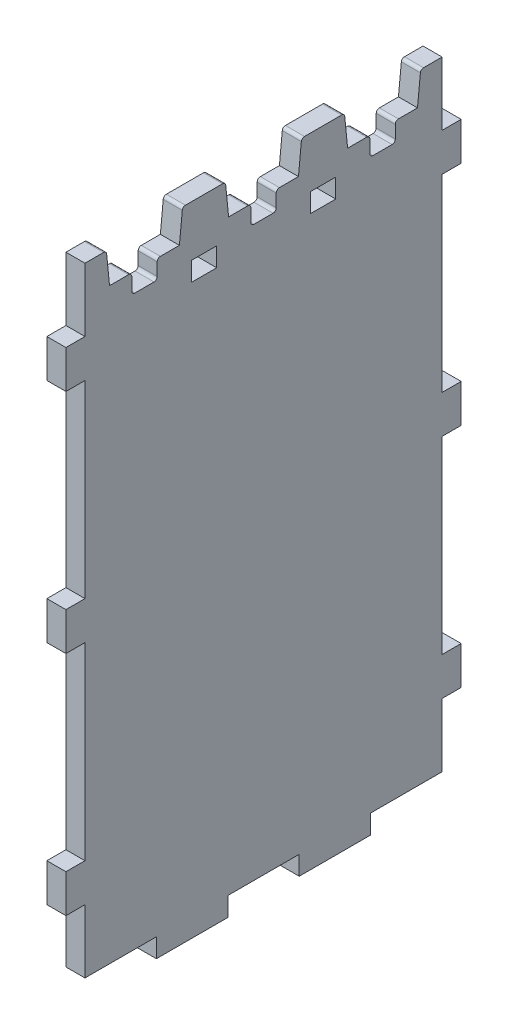
from build123d import *

# Parameters (mm, degrees)
BOSS_EXTRUDE2_DEPTH    = 6
FILLET1_R              = 1
LPATTERN1_COUNT        = 3
LPATTERN1_PITCH        = 37.5
FILLET1_OF_LPATTERN1_R = 1
SKETCH3_W              = 6
SKETCH3_H              = 12
BOSS_EXTRUDE3_DEPTH    = 6
SKETCH4_W              = 8
SKETCH4_H              = 6
CUT_EXTRUDE2_DEPTH     = 7
LPATTERN2_COUNT        = 2
LPATTERN2_PITCH        = 37.5
BOSS_EXTRUDE4_START    = -112.5
SKETCH3_2_W            = 6
SKETCH3_2_H            = 12
BOSS_EXTRUDE4_DEPTH    = 6
SKETCH5_W              = 6
SKETCH5_H              = 22.5
BOSS_EXTRUDE5_DEPTH    = 6


with BuildPart() as part:
    # Sketch2 → Boss-Extrude2 (new body)
    with BuildSketch(Plane(origin=(0, 0, 0), x_dir=(0, 0, -1), z_dir=(1, 0, 0))):
        Polygon((-18.75, 105.5), (-18.75, 89.5), (-18.75, -89.5), (18.75, -89.5), (18.75, 89.5), (18.75, 105.5), (12, 105.5), (11, 95.5), (4, 95.5), (4, 89.5), (-4, 89.5), (-4, 95.5), (-11, 95.5), (-12, 105.5), align=None)
    boss_extrude2 = extrude(amount=BOSS_EXTRUDE2_DEPTH)

    # Fillet1
    fillet1_edges = [part.edges().sort_by_distance(p)[0] for p in [
        (3, 95.5, -4),
        (3, 105.5, -12),
        (3, 105.5, 12),
        (3, 95.5, 4),
        (3, 89.5, 4),
        (3, 89.5, -4),
    ]]
    fillet(fillet1_edges, radius=FILLET1_R)

    # LPattern1: Boss-Extrude2 ×3
    with Locations(*[(0, 0, i * LPATTERN1_PITCH) for i in range(1, LPATTERN1_COUNT)]):
        add(boss_extrude2)

    # Fillet1 of LPattern1
    fillet1_of_lpattern1_edges = [part.edges().sort_by_distance(p)[0] for p in [
        (3, 95.5, 33.5),
        (3, 105.5, 25.5),
        (3, 105.5, 49.5),
        (3, 95.5, 41.5),
        (3, 89.5, 41.5),
        (3, 89.5, 33.5),
        (3, 95.5, 71),
        (3, 105.5, 63),
        (3, 105.5, 87),
        (3, 95.5, 79),
        (3, 89.5, 79),
        (3, 89.5, 71),
    ]]
    fillet(fillet1_of_lpattern1_edges, radius=FILLET1_OF_LPATTERN1_R)

    # Sketch3 → Boss-Extrude3 (add)
    with BuildSketch(Plane(origin=(0, 0, -18.75), x_dir=(-1, 0, 0), z_dir=(0, 0, -1))):
        with Locations((-3, 79.5)):
            Rectangle(SKETCH3_W, SKETCH3_H)
        with Locations((-3, -63.5)):
            Rectangle(SKETCH3_W, SKETCH3_H)
        with Locations((-3, 8)):
            Rectangle(SKETCH3_W, SKETCH3_H)
    extrude(amount=BOSS_EXTRUDE3_DEPTH)

    # Sketch4 → Cut-Extrude2 (cut, through all)
    with BuildSketch(Plane(origin=(0, 0, 0), x_dir=(0, 0, -1), z_dir=(1, 0, 0))):
        with Locations((-18.75, 86.5)):
            Rectangle(SKETCH4_W, SKETCH4_H)
    cut_extrude2 = extrude(amount=CUT_EXTRUDE2_DEPTH, mode=Mode.SUBTRACT)

    # LPattern2: Cut-Extrude2 ×2
    with Locations(*[(0, 0, i * LPATTERN2_PITCH) for i in range(1, LPATTERN2_COUNT)]):
        add(cut_extrude2, mode=Mode.SUBTRACT)

    # Sketch3_2 → Boss-Extrude4 (add)
    with BuildSketch(Plane(origin=(0, 0, -18.75), x_dir=(-1, 0, 0), z_dir=(0, 0, -1)).offset(BOSS_EXTRUDE4_START)):
        with Locations((-3, 79.5)):
            Rectangle(SKETCH3_2_W, SKETCH3_2_H)
        with Locations((-3, -63.5)):
            Rectangle(SKETCH3_2_W, SKETCH3_2_H)
        with Locations((-3, 8)):
            Rectangle(SKETCH3_2_W, SKETCH3_2_H)
    extrude(amount=-BOSS_EXTRUDE4_DEPTH)

    # Sketch5 → Boss-Extrude5 (add)
    with BuildSketch(Plane.XZ.offset(89.5)):
        with Locations((3, 15)):
            Rectangle(SKETCH5_W, SKETCH5_H)
        with Locations((3, 60)):
            Rectangle(SKETCH5_W, SKETCH5_H)
    extrude(amount=BOSS_EXTRUDE5_DEPTH)


solid = part.part
